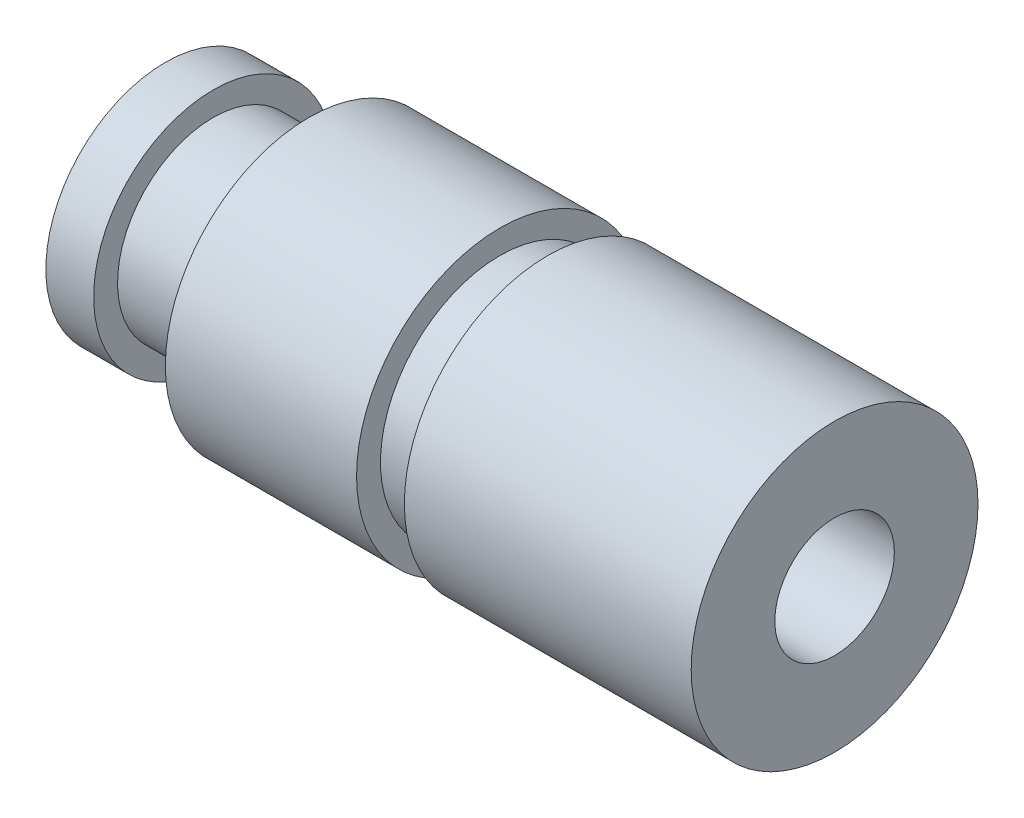
from build123d import *

# Parameters (mm, degrees)
TROU_TARAUD_M31_D       = 2.5
TROU_TARAUD_M31_DEPTH   = 8.5
TROU_TARAUD_M31_TIP     = 0.751075774
ESQUISSE4_R             = 3
ESQUISSE4_R_2           = 2.5
ENL_V_MAT_EXTRU_1_DEPTH = 0.5


with BuildPart() as part:
    # Esquisse1 → Révolution1 (revolve)
    with BuildSketch(Plane.XY):
        Polygon((0, 0), (0, 2.5), (1, 2.5), (1, 2), (3, 2), (3, 3), (14, 3), (14, 0), align=None)
    revolve(axis=Axis((14, 0, 0), (-1, 0, 0)))

    # Trou taraudé M31
    with Locations(Plane(origin=(14, 0, 0), x_dir=(0, 0, -1), z_dir=(1, 0, 0))):
        with Locations((0, 0)):
            Hole(TROU_TARAUD_M31_D / 2, depth=TROU_TARAUD_M31_DEPTH)
            with Locations((0, 0, -(TROU_TARAUD_M31_DEPTH + TROU_TARAUD_M31_TIP / 2))):  # 118° drill point
                Cone(0, TROU_TARAUD_M31_D / 2, TROU_TARAUD_M31_TIP, mode=Mode.SUBTRACT)

    # Esquisse4 → Enlèv. mat.-Extru.1 (cut, symmetric)
    with BuildSketch(Plane.ZY.offset(-7.5)):
        Circle(ESQUISSE4_R)
        Circle(ESQUISSE4_R_2, mode=Mode.SUBTRACT)
    extrude(amount=ENL_V_MAT_EXTRU_1_DEPTH, both=True, mode=Mode.SUBTRACT)


solid = part.part
